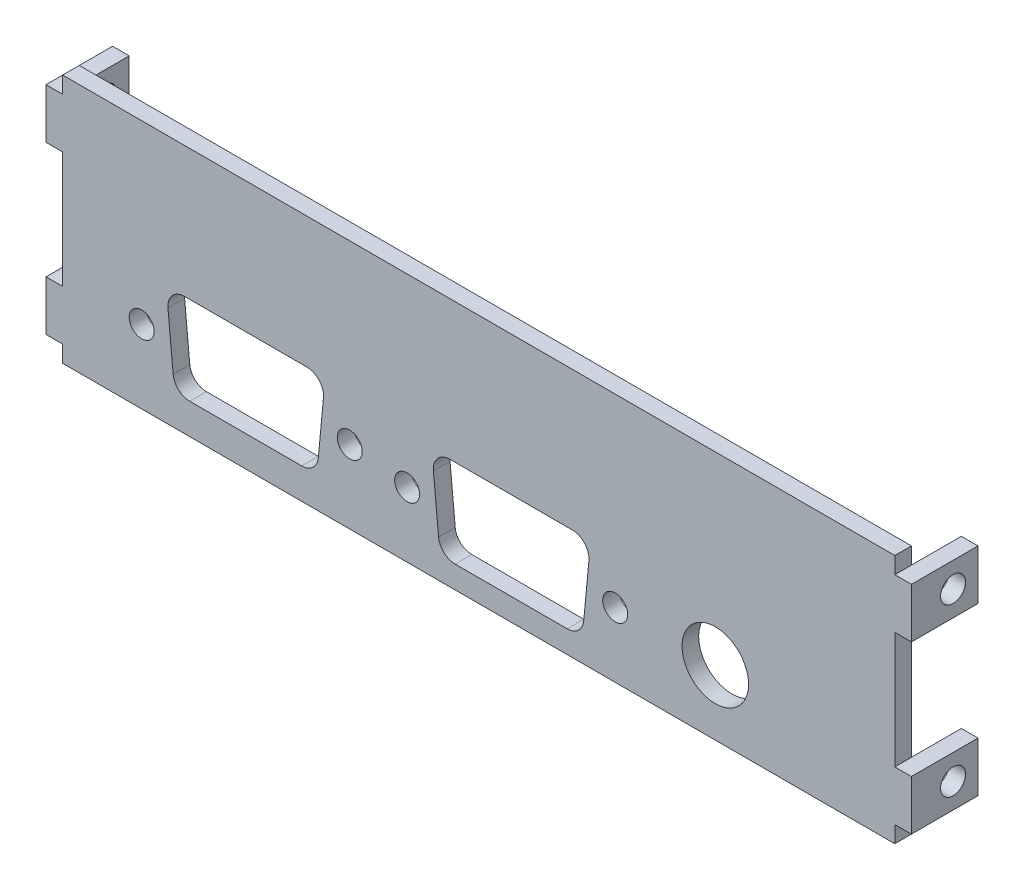
from build123d import *

# Parameters (mm, degrees)
SKETCH1_W           = 100
SKETCH1_H           = 30
BOSS_EXTRUDE1_DEPTH = 2
SKETCH2_W           = 2
SKETCH2_H           = 6
BOSS_EXTRUDE2_DEPTH = 8
SKETCH3_R           = 1.5
CUT_EXTRUDE1_DEPTH  = 105
CUT_EXTRUDE2_REACH  = 10
SKETCH4_R           = 1.5
SKETCH4_R_2         = 4


with BuildPart() as part:
    # Sketch1 → Boss-Extrude1 (new body)
    with BuildSketch(Plane.XY):
        Rectangle(SKETCH1_W, SKETCH1_H)
    extrude(amount=BOSS_EXTRUDE1_DEPTH)

    # Sketch2 → Boss-Extrude2 (add)
    with BuildSketch(Plane.XY.offset(2)):
        with Locations((-51, 10)):
            Rectangle(SKETCH2_W, SKETCH2_H)
        with Locations((-51, -10)):
            Rectangle(SKETCH2_W, SKETCH2_H)
        with Locations((51, 10)):
            Rectangle(SKETCH2_W, SKETCH2_H)
        with Locations((51, -10)):
            Rectangle(SKETCH2_W, SKETCH2_H)
    extrude(amount=-BOSS_EXTRUDE2_DEPTH)

    # Sketch3 → Cut-Extrude1 (cut, through all)
    with BuildSketch(Plane.ZY.offset(52)):
        with Locations((-3, 10)):
            Circle(SKETCH3_R)
        with Locations((-3, -10)):
            Circle(SKETCH3_R)
    extrude(amount=-CUT_EXTRUDE1_DEPTH, mode=Mode.SUBTRACT)

    # Sketch4 → Cut-Extrude2 (cut, up to next)
    with BuildSketch(Plane.XY.offset(2), mode=Mode.PRIVATE) as cut_extrude2_sk1:
        with Locations((-40.502306205, -6.199754272)):
            Circle(SKETCH4_R)
    cut_extrude2_tool1 = extrude(cut_extrude2_sk1.sketch, amount=-CUT_EXTRUDE2_REACH, mode=Mode.PRIVATE) & part.part
    add(cut_extrude2_tool1.solids().sort_by_distance((-40.502306, -6.199754, 2))[0], mode=Mode.SUBTRACT)
    # Sketch4 → Cut-Extrude2 (cut, up to next)
    with BuildSketch(Plane.XY.offset(2), mode=Mode.PRIVATE) as cut_extrude2_sk2:
        with Locations((-15.497693795, -6.199754272)):
            Circle(SKETCH4_R)
    cut_extrude2_tool2 = extrude(cut_extrude2_sk2.sketch, amount=-CUT_EXTRUDE2_REACH, mode=Mode.PRIVATE) & part.part
    add(cut_extrude2_tool2.solids().sort_by_distance((-15.497694, -6.199754, 2))[0], mode=Mode.SUBTRACT)
    # Sketch4 → Cut-Extrude2 (cut, up to next)
    with BuildSketch(Plane.XY.offset(2), mode=Mode.PRIVATE) as cut_extrude2_sk3:
        with Locations((-8.604808795, -7.2)):
            Circle(SKETCH4_R)
    cut_extrude2_tool3 = extrude(cut_extrude2_sk3.sketch, amount=-CUT_EXTRUDE2_REACH, mode=Mode.PRIVATE) & part.part
    add(cut_extrude2_tool3.solids().sort_by_distance((-8.604809, -7.2, 2))[0], mode=Mode.SUBTRACT)
    # Sketch4 → Cut-Extrude2 (cut, up to next)
    with BuildSketch(Plane.XY.offset(2), mode=Mode.PRIVATE) as cut_extrude2_sk4:
        with Locations((16.399709937, -7.2)):
            Circle(SKETCH4_R)
    cut_extrude2_tool4 = extrude(cut_extrude2_sk4.sketch, amount=-CUT_EXTRUDE2_REACH, mode=Mode.PRIVATE) & part.part
    add(cut_extrude2_tool4.solids().sort_by_distance((16.39971, -7.2, 2))[0], mode=Mode.SUBTRACT)
    # Sketch4 → Cut-Extrude2 (cut, up to next)
    with BuildSketch(Plane.XY.offset(2), mode=Mode.PRIVATE) as cut_extrude2_sk5:
        with Locations((28.430538533, -7.2)):
            Circle(SKETCH4_R_2)
    cut_extrude2_tool5 = extrude(cut_extrude2_sk5.sketch, amount=-CUT_EXTRUDE2_REACH, mode=Mode.PRIVATE) & part.part
    add(cut_extrude2_tool5.solids().sort_by_distance((28.430539, -7.2, 2))[0], mode=Mode.SUBTRACT)
    # Sketch4 → Cut-Extrude2 (cut, up to next)
    with BuildSketch(Plane.XY.offset(2), mode=Mode.PRIVATE) as cut_extrude2_sk6:
        with BuildLine():
            Line((-35.352440505, -0.712200048), (-20.647559495, -0.712200048))
            ThreePointArc((-20.647559495, -0.712200048), (-19.168422859, -1.366037052), (-18.65640049, -2.900045237))
            Line((-18.65640049, -2.900045237), (-19.2789871, -9.499463306))
            ThreePointArc((-19.2789871, -9.499463306), (-19.92398311, -10.790754753), (-21.270146105, -11.311618117))
            Line((-21.270146105, -11.311618117), (-34.729853895, -11.311618117))
            ThreePointArc((-34.729853895, -11.311618117), (-36.07601689, -10.790754753), (-36.7210129, -9.499463306))
            Line((-36.7210129, -9.499463306), (-37.34359951, -2.900045237))
            ThreePointArc((-37.34359951, -2.900045237), (-36.831577141, -1.366037052), (-35.352440505, -0.712200048))
        make_face()
    cut_extrude2_tool6 = extrude(cut_extrude2_sk6.sketch, amount=-CUT_EXTRUDE2_REACH, mode=Mode.PRIVATE) & part.part
    add(cut_extrude2_tool6.solids().sort_by_distance((-28, -5.931102, 2))[0], mode=Mode.SUBTRACT)
    # Sketch4 → Cut-Extrude2 (cut, up to next)
    with BuildSketch(Plane.XY.offset(2), mode=Mode.PRIVATE) as cut_extrude2_sk7:
        with BuildLine():
            Line((-3.454989934, -1.718769673), (11.249891076, -1.718769673))
            ThreePointArc((11.249891076, -1.718769673), (12.729090854, -2.372676058), (13.241032451, -3.906801654))
            Line((13.241032451, -3.906801654), (12.618390941, -10.500186773))
            ThreePointArc((12.618390941, -10.500186773), (11.973343181, -11.791354569), (10.627249567, -12.312154791))
            Line((10.627249567, -12.312154791), (-2.832348424, -12.312154791))
            ThreePointArc((-2.832348424, -12.312154791), (-4.178442039, -11.791354569), (-4.823489799, -10.500186773))
            Line((-4.823489799, -10.500186773), (-5.446131309, -3.906801654))
            ThreePointArc((-5.446131309, -3.906801654), (-4.934189711, -2.372676058), (-3.454989934, -1.718769673))
        make_face()
    cut_extrude2_tool7 = extrude(cut_extrude2_sk7.sketch, amount=-CUT_EXTRUDE2_REACH, mode=Mode.PRIVATE) & part.part
    add(cut_extrude2_tool7.solids().sort_by_distance((3.897451, -6.934685, 2))[0], mode=Mode.SUBTRACT)


solid = part.part
